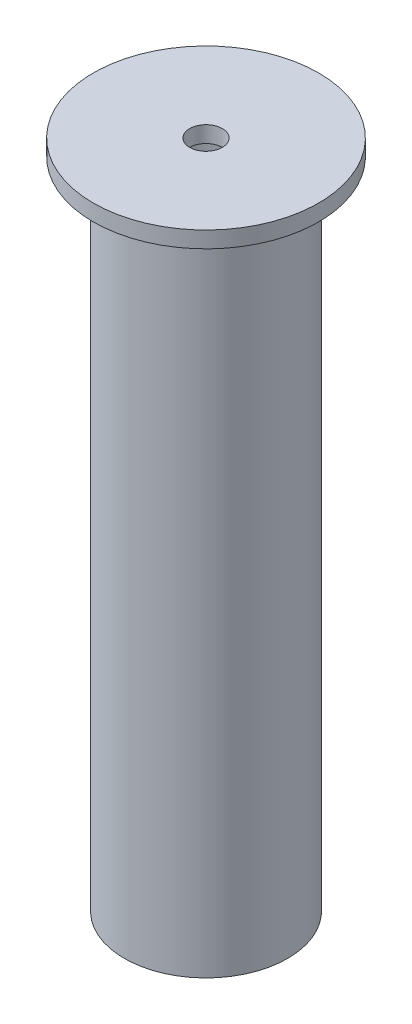
from build123d import *


with BuildPart() as part:
    # Esboço1 → Revolução1 (revolve)
    with BuildSketch(Plane.XY):
        Polygon((10, 410), (69, 410), (69, 400), (50, 400), (50, 0), (38, 0), (38, 10), (44, 10), (44, 400), (10, 400), align=None)
    revolve(axis=Axis((0, 0, 0), (0, 1, 0)))


solid = part.part
